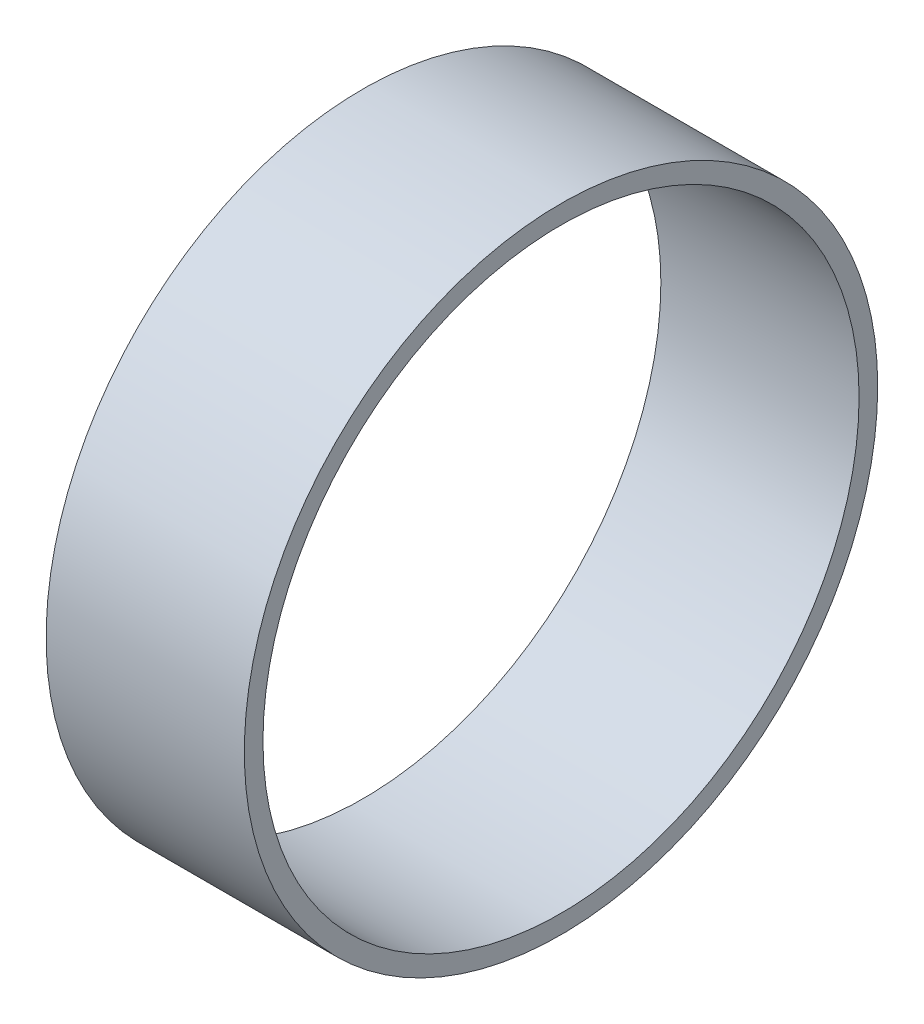
from build123d import *

# Parameters (mm, degrees)
SKETCH1_R           = 53.975
SKETCH1_R_2         = 50.8
BOSS_EXTRUDE1_DEPTH = 33.782


with BuildPart() as part:
    # Sketch1 → Boss-Extrude1 (new body)
    with BuildSketch(Plane(origin=(0, 0, 0), x_dir=(0, 0, -1), z_dir=(1, 0, 0))):
        Circle(SKETCH1_R)
        Circle(SKETCH1_R_2, mode=Mode.SUBTRACT)
    extrude(amount=BOSS_EXTRUDE1_DEPTH)


solid = part.part
